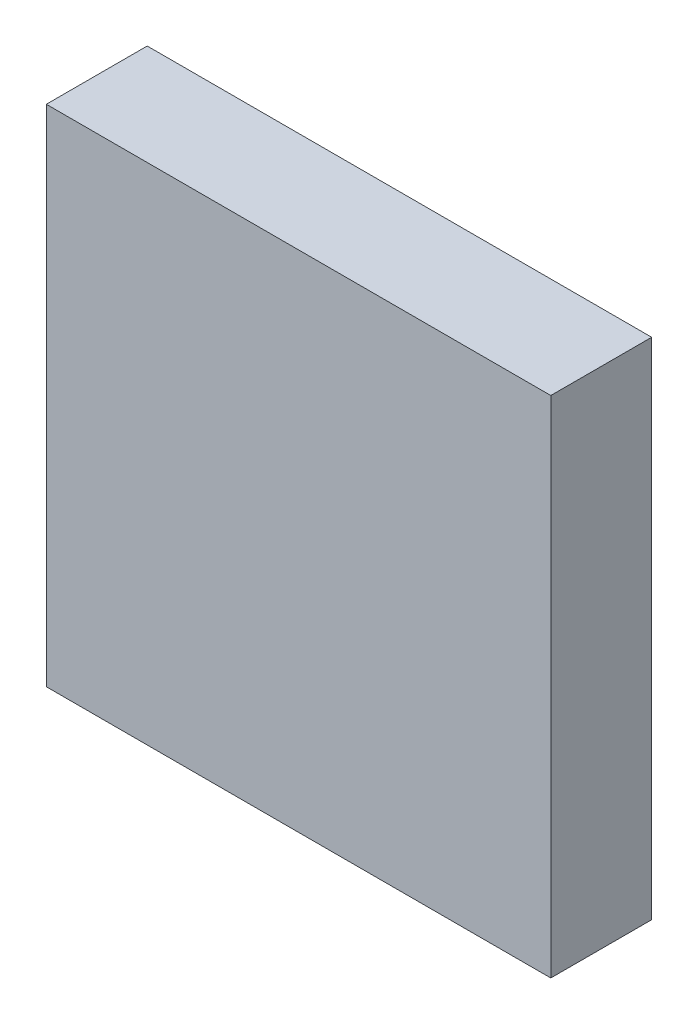
from build123d import *

# Parameters (mm, degrees)
EXTRUDE_1_DEPTH = 10


with BuildPart() as part:
    # 草图1 → 凸台-拉伸1 (new body)
    with BuildSketch(Plane.XY):
        Polygon((416.617543458, 154.384302534), (416.617543458, 179.384302534), (466.617543458, 179.384302534), (466.617543458, 129.384302534), (416.617543458, 129.384302534), align=None)
    extrude(amount=EXTRUDE_1_DEPTH)


solid = part.part
